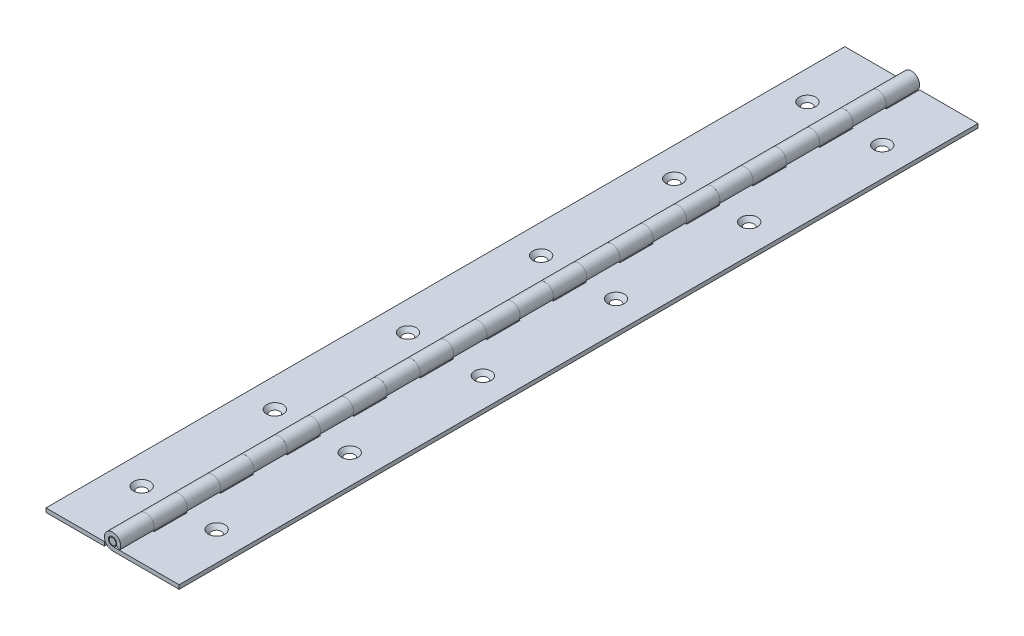
from build123d import *

# Parameters (mm, degrees)
EXTRUDE1_DEPTH          = 152.4
SKETCH3_W               = 6.223
SKETCH3_H               = 12.7
CUT_EXTRUDE1_DEPTH      = 25.4
LPATTERN1_COUNT         = 12
LPATTERN1_PITCH         = 25.4
EXTRUDE2_DEPTH          = 12.7
LPATTERN3_COUNT         = 12
LPATTERN3_PITCH         = 25.4
SKETCH6_W               = 22.2631
SKETCH6_H               = 1.524
EXTRUDE5_DEPTH          = 304.8
SKETCH10_R              = 1.8288
CUT_EXTRUDE2_DEPTH      = 7.223
CUT_EXTRUDE2_TAPER      = -41
LPATTERN4_COUNT         = 6
LPATTERN4_PITCH         = 50.8
MIRROR3_COPY_1_SKETCH_R = 1.8288
MIRROR3_COPY_1_DEPTH    = 7.223
MIRROR3_COPY_1_TAPER    = -41
MIRROR3_COPY_2_SKETCH_R = 1.8288
MIRROR3_COPY_2_DEPTH    = 7.223
MIRROR3_COPY_2_TAPER    = -41
MIRROR3_COPY_3_SKETCH_R = 1.8288
MIRROR3_COPY_3_DEPTH    = 7.223
MIRROR3_COPY_3_TAPER    = -41
MIRROR3_COPY_4_SKETCH_R = 1.8288
MIRROR3_COPY_4_DEPTH    = 7.223
MIRROR3_COPY_4_TAPER    = -41
MIRROR3_COPY_5_SKETCH_R = 1.8288
MIRROR3_COPY_5_DEPTH    = 7.223
MIRROR3_COPY_5_TAPER    = -41
SKETCH7_R               = 1.5875
EXTRUDE4_DEPTH          = 152.4
CHAMFER1_SIZE           = 0.3175


with BuildPart() as part:
    # Sketch2 → Extrude1 (new body, symmetric)
    with BuildSketch(Plane.XY):
        with BuildLine():
            Line((25.4, -1.5875), (25.4, -3.1115))
            Line((25.4, -3.1115), (0, -3.1115))
            ThreePointArc((0, -3.1115), (-1.671807731, 2.624212484), (2.819976679, -1.314976721))
            Line((2.819976679, -1.314976721), (1.438763612, -0.670906491))
            ThreePointArc((1.438763612, -0.670906491), (-0.852963128, 1.33888392), (0, -1.5875))
            Line((0, -1.5875), (25.4, -1.5875))
        make_face()
    extrude(amount=EXTRUDE1_DEPTH, both=True)

    # Sketch3 → Cut-Extrude1 (cut, symmetric)
    with BuildSketch(Plane(origin=(0, -1.5875, 0), x_dir=(1, 0, 0), z_dir=(0, 1, 0))):
        with Locations((0, 146.05)):
            Rectangle(SKETCH3_W, SKETCH3_H)
    cut_extrude1 = extrude(amount=CUT_EXTRUDE1_DEPTH, both=True, mode=Mode.SUBTRACT)

    # LPattern1: Cut-Extrude1 ×12
    with Locations(*[(0, 0, i * LPATTERN1_PITCH) for i in range(1, LPATTERN1_COUNT)]):
        add(cut_extrude1, mode=Mode.SUBTRACT)

    # Sketch10 → Cut-Extrude2 (cut, through all)
    with BuildSketch(Plane(origin=(0, -3.1115, 0), x_dir=(1, 0, 0), z_dir=(0, 1, 0))):
        with Locations((14.2875, 127)):
            Circle(SKETCH10_R)
    cut_extrude2 = extrude(amount=CUT_EXTRUDE2_DEPTH, taper=CUT_EXTRUDE2_TAPER, mode=Mode.SUBTRACT)

    # LPattern4: Cut-Extrude2 ×6
    with Locations(*[(0, 0, i * LPATTERN4_PITCH) for i in range(1, LPATTERN4_COUNT)]):
        add(cut_extrude2, mode=Mode.SUBTRACT)


with BuildPart() as body_2:
    # Sketch5 → Extrude2 (new body)
    with BuildSketch(Plane(origin=(0, 0, -152.4), x_dir=(-1, 0, 0), z_dir=(0, 0, -1))):
        with BuildLine():
            Line((0, -1.5875), (25.4, -1.5875))
            Line((25.4, -1.5875), (25.4, -3.1115))
            Line((25.4, -3.1115), (0, -3.1115))
            ThreePointArc((0, -3.1115), (-1.671807731, 2.624212484), (2.819976679, -1.314976721))
            Line((2.819976679, -1.314976721), (1.438763612, -0.670906491))
            ThreePointArc((1.438763612, -0.670906491), (-0.852963128, 1.33888392), (0, -1.5875))
        make_face()
    extrude(amount=-EXTRUDE2_DEPTH)


with BuildPart() as lpattern3_1:
    # LPattern3: pattern copy
    add(body_2.part.moved(Location(Vector(0, 0, 1) * (1 * LPATTERN3_PITCH))))


with BuildPart() as lpattern3_2:
    # LPattern3: pattern copy
    add(body_2.part.moved(Location(Vector(0, 0, 1) * (2 * LPATTERN3_PITCH))))


with BuildPart() as lpattern3_3:
    # LPattern3: pattern copy
    add(body_2.part.moved(Location(Vector(0, 0, 1) * (3 * LPATTERN3_PITCH))))


with BuildPart() as lpattern3_4:
    # LPattern3: pattern copy
    add(body_2.part.moved(Location(Vector(0, 0, 1) * (4 * LPATTERN3_PITCH))))


with BuildPart() as lpattern3_5:
    # LPattern3: pattern copy
    add(body_2.part.moved(Location(Vector(0, 0, 1) * (5 * LPATTERN3_PITCH))))


with BuildPart() as lpattern3_6:
    # LPattern3: pattern copy
    add(body_2.part.moved(Location(Vector(0, 0, 1) * (6 * LPATTERN3_PITCH))))


with BuildPart() as lpattern3_7:
    # LPattern3: pattern copy
    add(body_2.part.moved(Location(Vector(0, 0, 1) * (7 * LPATTERN3_PITCH))))


with BuildPart() as lpattern3_8:
    # LPattern3: pattern copy
    add(body_2.part.moved(Location(Vector(0, 0, 1) * (8 * LPATTERN3_PITCH))))


with BuildPart() as lpattern3_9:
    # LPattern3: pattern copy
    add(body_2.part.moved(Location(Vector(0, 0, 1) * (9 * LPATTERN3_PITCH))))


with BuildPart() as lpattern3_10:
    # LPattern3: pattern copy
    add(body_2.part.moved(Location(Vector(0, 0, 1) * (10 * LPATTERN3_PITCH))))


with BuildPart() as lpattern3_11:
    # LPattern3: pattern copy
    add(body_2.part.moved(Location(Vector(0, 0, 1) * (11 * LPATTERN3_PITCH))))


with BuildPart() as body_2_1:
    add(body_2.part)

    add(lpattern3_1.part)  # Extrude5 merges LPattern3_1

    add(lpattern3_2.part)  # Extrude5 merges LPattern3_2

    add(lpattern3_3.part)  # Extrude5 merges LPattern3_3

    add(lpattern3_4.part)  # Extrude5 merges LPattern3_4

    add(lpattern3_5.part)  # Extrude5 merges LPattern3_5

    add(lpattern3_6.part)  # Extrude5 merges LPattern3_6

    add(lpattern3_7.part)  # Extrude5 merges LPattern3_7

    add(lpattern3_8.part)  # Extrude5 merges LPattern3_8

    add(lpattern3_9.part)  # Extrude5 merges LPattern3_9

    add(lpattern3_10.part)  # Extrude5 merges LPattern3_10

    add(lpattern3_11.part)  # Extrude5 merges LPattern3_11
    # Sketch6 → Extrude5 (add)
    with BuildSketch(Plane(origin=(0, 0, -152.4), x_dir=(-1, 0, 0), z_dir=(0, 0, -1))):
        with Locations((14.26845, -2.3495)):
            Rectangle(SKETCH6_W, SKETCH6_H)
    extrude(amount=-EXTRUDE5_DEPTH)

    # Mirror3: Cut-Extrude2 across plane
    add(cut_extrude2.mirror(Plane(origin=(0, 0, 0), x_dir=(0, 0, 1), z_dir=(1, 0, 0))), mode=Mode.SUBTRACT)

    # Mirror3 copy 1 sketch → Mirror3 copy 1 (cut, through all)
    with BuildSketch(Plane(origin=(0, -3.1115, 50.8), x_dir=(-1, 0, 0), z_dir=(0, 1, 0))):
        with Locations((14.2875, -127)):
            Circle(MIRROR3_COPY_1_SKETCH_R)
    extrude(amount=MIRROR3_COPY_1_DEPTH, taper=MIRROR3_COPY_1_TAPER, mode=Mode.SUBTRACT)

    # Mirror3 copy 2 sketch → Mirror3 copy 2 (cut, through all)
    with BuildSketch(Plane(origin=(0, -3.1115, 101.6), x_dir=(-1, 0, 0), z_dir=(0, 1, 0))):
        with Locations((14.2875, -127)):
            Circle(MIRROR3_COPY_2_SKETCH_R)
    extrude(amount=MIRROR3_COPY_2_DEPTH, taper=MIRROR3_COPY_2_TAPER, mode=Mode.SUBTRACT)

    # Mirror3 copy 3 sketch → Mirror3 copy 3 (cut, through all)
    with BuildSketch(Plane(origin=(0, -3.1115, 152.4), x_dir=(-1, 0, 0), z_dir=(0, 1, 0))):
        with Locations((14.2875, -127)):
            Circle(MIRROR3_COPY_3_SKETCH_R)
    extrude(amount=MIRROR3_COPY_3_DEPTH, taper=MIRROR3_COPY_3_TAPER, mode=Mode.SUBTRACT)

    # Mirror3 copy 4 sketch → Mirror3 copy 4 (cut, through all)
    with BuildSketch(Plane(origin=(0, -3.1115, 203.2), x_dir=(-1, 0, 0), z_dir=(0, 1, 0))):
        with Locations((14.2875, -127)):
            Circle(MIRROR3_COPY_4_SKETCH_R)
    extrude(amount=MIRROR3_COPY_4_DEPTH, taper=MIRROR3_COPY_4_TAPER, mode=Mode.SUBTRACT)

    # Mirror3 copy 5 sketch → Mirror3 copy 5 (cut, through all)
    with BuildSketch(Plane(origin=(0, -3.1115, 254), x_dir=(-1, 0, 0), z_dir=(0, 1, 0))):
        with Locations((14.2875, -127)):
            Circle(MIRROR3_COPY_5_SKETCH_R)
    extrude(amount=MIRROR3_COPY_5_DEPTH, taper=MIRROR3_COPY_5_TAPER, mode=Mode.SUBTRACT)


with BuildPart() as body_3:
    # Sketch7 → Extrude4 (new body, symmetric)
    with BuildSketch(Plane.XY):
        Circle(SKETCH7_R)
    extrude(amount=EXTRUDE4_DEPTH, both=True)

    # Chamfer1
    chamfer1_edges = [body_3.edges().sort_by_distance(p)[0] for p in [
        (-1.5875, 0, -152.4),
        (-1.5875, 0, 152.4),
    ]]
    chamfer(chamfer1_edges, length=CHAMFER1_SIZE)


solid = Compound([part.part, body_2_1.part, body_3.part])
